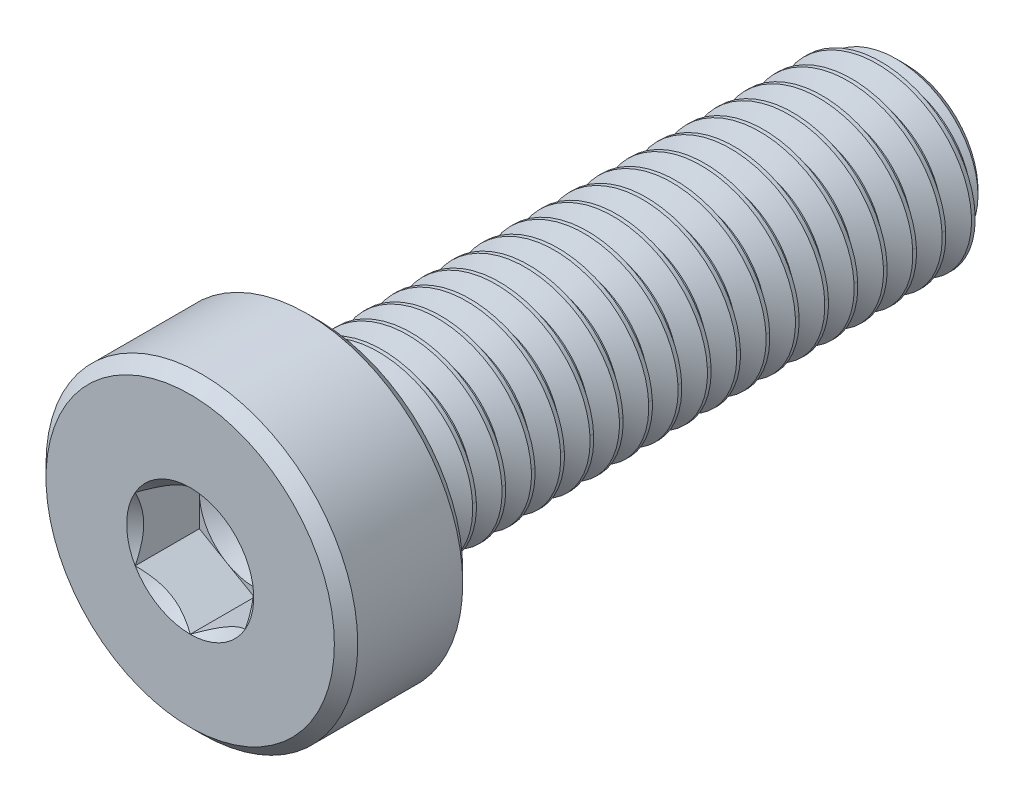
from build123d import *

# Parameters (mm, degrees)
CUT_EXTRUDE1_DEPTH     = 1.75
CUT_SWEEP1_PITCH       = 0.8
CUT_SWEEP1_HEIGHT      = 16.5
CUT_SWEEP1_RADIUS      = 2.5
CUT_SWEEP1_START_ANGLE = 90


with BuildPart() as part:
    # Sketch2 → Revolve1 (revolve)
    with BuildSketch(Plane(origin=(0, 0, 0), x_dir=(0, 0, -1), z_dir=(1, 0, 0)), mode=Mode.PRIVATE) as revolve1_sk:
        with BuildLine():
            Line((-6.56875, 4.25), (-6.25, 3.93125))
            Line((-6.25, 3.93125), (-6.25, 2.75))
            ThreePointArc((-6.25, 2.75), (-6.176776695, 2.573223305), (-6, 2.5))
            Line((-6, 2.5), (9.230384758, 2.5))
            Line((9.230384758, 2.5), (9.75, 1.980384758))
            Line((9.75, 1.980384758), (9.75, 0))
            Line((9.75, 0), (-8, 0))
            Line((-8, 0), (-8, 1.5))
            Line((-8, 1.5), (-9.75, 1.5))
            Line((-9.75, 1.5), (-9.75, 3.93125))
            Line((-9.75, 3.93125), (-9.43125, 4.25))
            Line((-9.43125, 4.25), (-6.56875, 4.25))
        make_face()
    revolve(revolve1_sk.sketch.rotate(Axis((0, 0, 8), (0, 0, -1)), 90), axis=Axis((0, 0, 8), (0, 0, -1)))

    # Sketch3 → Cut-Extrude1 (cut)
    with BuildSketch(Plane.XY.offset(9.75)):
        Polygon((0, 1.732050808), (-1.5, 0.866025404), (-1.5, -0.866025404), (0, -1.732050808), (1.5, -0.866025404), (1.5, 0.866025404), align=None)
    extrude(amount=-CUT_EXTRUDE1_DEPTH, mode=Mode.SUBTRACT)

    # Cut-Extrude2 cone 1 section (through the dimple's axis) → Cut-Extrude2 (revolve, cut)
    with BuildSketch(Plane(origin=(0, 0, 9.75), x_dir=(0, -1, 0), z_dir=(1, 0, 0))):
        Polygon((0, 0), (1.732050808, 0), (0, 1.732050808), align=None)
    revolve(axis=Axis((0, 0, 9.75), (0, 0, -1)), mode=Mode.SUBTRACT)

    # Cut-Extrude5 cone 1 section (through the dimple's axis) → Cut-Extrude5 (revolve, cut)
    with BuildSketch(Plane(origin=(0, 0, 8), x_dir=(0, -1, 0), z_dir=(1, 0, 0))):
        Polygon((0, 0), (1.5, 0), (0, 0.866025404), align=None)
    revolve(axis=Axis((0, 0, 8), (0, 0, -1)), mode=Mode.SUBTRACT)

    # Cut-Sweep1: sweep along a helix
    with BuildLine() as cut_sweep1_path:
        add(Helix(CUT_SWEEP1_PITCH, CUT_SWEEP1_HEIGHT, CUT_SWEEP1_RADIUS, center=(0, 0, -9.75), direction=(0, 0, 1), mode=Mode.PRIVATE).rotate(Axis((0, 0, -9.75), (0, 0, 1)), CUT_SWEEP1_START_ANGLE))
    # Sketch8 → Cut-Sweep1 (sweep, cut)
    with BuildSketch(Plane(origin=(0, 0, 0), x_dir=(0, 0, -1), z_dir=(1, 0, 0))):
        Polygon((9.725, 2.54330127), (10.475, 2.54330127), (10.15, 1.980384758), (10.05, 1.980384758), align=None)
    sweep(path=cut_sweep1_path.line, is_frenet=True, mode=Mode.SUBTRACT)

    # Sketch9 → Revolve2 (revolve)
    with BuildSketch(Plane(origin=(0, 0, 0), x_dir=(0, 0, -1), z_dir=(1, 0, 0)), mode=Mode.PRIVATE) as revolve2_sk:
        with BuildLine():
            Line((-6.8, 0), (-6.8, 2.75))
            Line((-6.8, 2.75), (-6.25, 2.75))
            ThreePointArc((-6.25, 2.75), (-6.176776695, 2.573223305), (-6, 2.5))
            Line((-6, 2.5), (-5.45, 2.5))
            Line((-5.45, 2.5), (-4.006624327, 0))
            Line((-4.006624327, 0), (-6.8, 0))
        make_face()
    revolve(revolve2_sk.sketch.rotate(Axis((0, 0, 4.006624327), (0, 0, 1)), 270), axis=Axis((0, 0, 4.006624327), (0, 0, 1)))


solid = part.part
